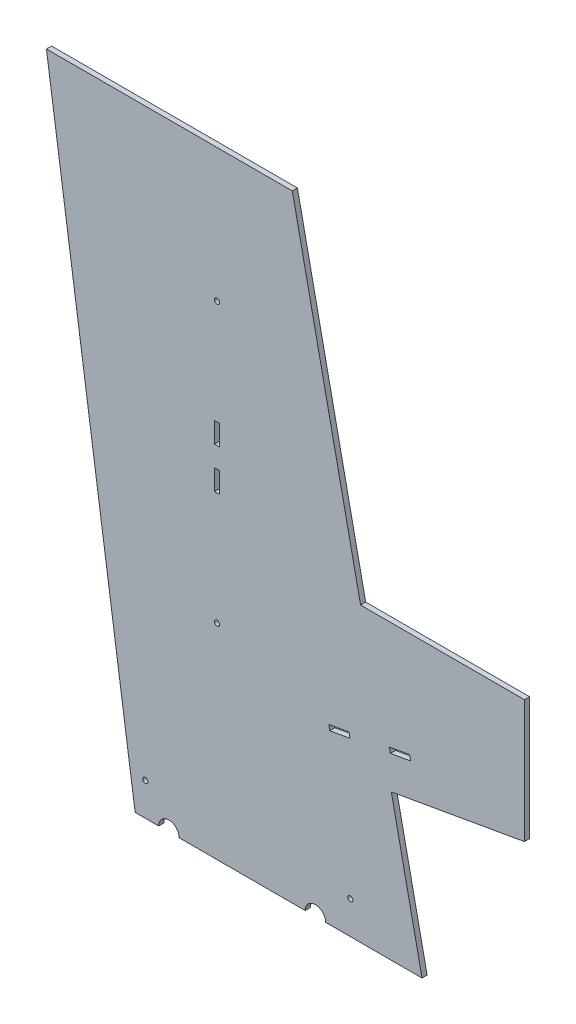
from build123d import *

# Parameters (mm, degrees)
BOSS_EXTRUDE1_DEPTH = 3.175
SKETCH2_R           = 1.5875
CUT_EXTRUDE1_DEPTH  = 3.175
BOSS_EXTRUDE2_DEPTH = 3.175
CUT_EXTRUDE2_DEPTH  = 3.175
SKETCH5_W           = 1.5875
SKETCH5_H           = 12.7
CUT_EXTRUDE3_DEPTH  = 10.16
LPATTERN1_COUNT     = 2
LPATTERN1_PITCH     = 25.4
SKETCH9_R           = 1.5875
CUT_EXTRUDE7_DEPTH  = 7.62
SKETCH10_R          = 6.35
CUT_EXTRUDE8_DEPTH  = 5.08


with BuildPart() as part:
    # Sketch1 → Boss-Extrude1 (new body)
    with BuildSketch(Plane.XY):
        Polygon((0, 0), (-177.8, 0), (-232.7656, 382.27), (-80.3656, 382.27), align=None)
    extrude(amount=BOSS_EXTRUDE1_DEPTH)

    # Sketch2 → Cut-Extrude1 (cut)
    with BuildSketch(Plane.XY.offset(3.175)):
        with Locations((-127, 127)):
            Circle(SKETCH2_R)
        with Locations((-127, 299.72)):
            Circle(SKETCH2_R)
    extrude(amount=-CUT_EXTRUDE1_DEPTH, mode=Mode.SUBTRACT)

    # Sketch3 → Boss-Extrude2 (add)
    with BuildSketch(Plane.XY.offset(3.175)):
        Polygon((-63.5, 82.55), (63.5, 104.94352655), (63.5, 181.14352655), (-63.5, 181.14352655), align=None)
    extrude(amount=-BOSS_EXTRUDE2_DEPTH)

    # Sketch4 → Cut-Extrude2 (cut)
    with BuildSketch(Plane.XY.offset(3.175)):
        Polygon((-57.15, 104.14), (-44.642941537, 106.345331856), (-45.194274501, 109.472096472), (-57.701332964, 107.266764616), align=None)
        Polygon((-19.62882461, 110.755995569), (-7.121766147, 112.961327425), (-7.673099111, 116.088092041), (-20.180157574, 113.882760185), align=None)
    extrude(amount=-CUT_EXTRUDE2_DEPTH, mode=Mode.SUBTRACT)

    # Sketch5 → Cut-Extrude3 (cut)
    with BuildSketch(Plane.XY.offset(3.175)):
        with Locations((-126.20625, 203.2)):
            Rectangle(SKETCH5_W, SKETCH5_H)
        with Locations((-127.79375, 203.2)):
            Rectangle(SKETCH5_W, SKETCH5_H)
    cut_extrude3 = extrude(amount=-CUT_EXTRUDE3_DEPTH, mode=Mode.SUBTRACT)

    # LPattern1: Cut-Extrude3 ×2
    with Locations(*[(0, i * LPATTERN1_PITCH, 0) for i in range(1, LPATTERN1_COUNT)]):
        add(cut_extrude3, mode=Mode.SUBTRACT)

    # Sketch9 → Cut-Extrude7 (cut)
    with BuildSketch(Plane(origin=(0, 0, 0), x_dir=(-1, 0, 0), z_dir=(0, 0, -1))):
        with Locations((171.45, 20.32)):
            Circle(SKETCH9_R)
        with Locations((44.45, 20.32)):
            Circle(SKETCH9_R)
    extrude(amount=-CUT_EXTRUDE7_DEPTH, mode=Mode.SUBTRACT)

    # Sketch10 → Cut-Extrude8 (cut)
    with BuildSketch(Plane(origin=(0, 0, 0), x_dir=(-1, 0, 0), z_dir=(0, 0, -1))):
        with Locations((156.845, 0)):
            Circle(SKETCH10_R)
        with Locations((66.04, 0)):
            Circle(SKETCH10_R)
    extrude(amount=-CUT_EXTRUDE8_DEPTH, mode=Mode.SUBTRACT)


solid = part.part
